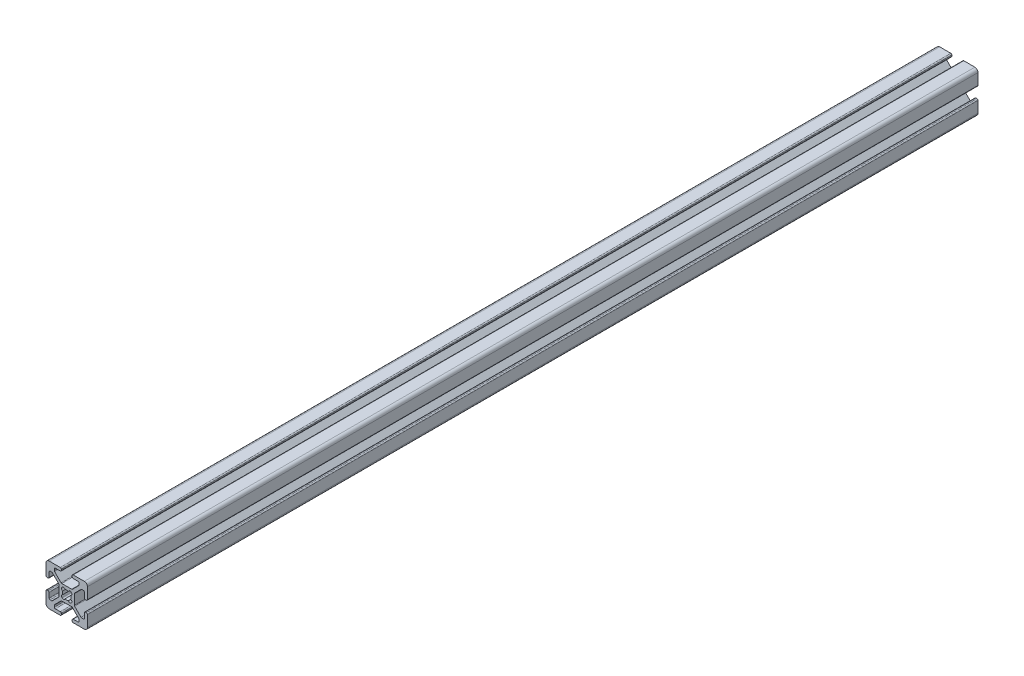
from build123d import *

# Parameters (mm, degrees)
EXTRUDE1_DEPTH = 430


with BuildPart() as part:
    # Sketch1 → Extrude1 (new body)
    with BuildSketch(Plane.XY):
        with BuildLine():
            Line((9.492, 2.63), (9.008, 2.63))
            ThreePointArc((9.008, 2.63), (8.648789755, 2.778789755), (8.5, 3.138))
            Line((8.5, 3.138), (8.5, 5.487))
            ThreePointArc((8.5, 5.487), (8.351210245, 5.846210245), (7.992, 5.995))
            Line((7.992, 5.995), (7.266080661, 5.995))
            ThreePointArc((7.266080661, 5.995), (7.071677478, 5.956330803), (6.906870417, 5.846210245))
            Line((6.906870417, 5.846210245), (3.803789755, 2.743129583))
            ThreePointArc((3.803789755, 2.743129583), (3.693669197, 2.578322522), (3.655, 2.383919339))
            Line((3.655, 2.383919339), (3.655, -2.383919339))
            ThreePointArc((3.655, -2.383919339), (3.693669197, -2.578322522), (3.803789755, -2.743129583))
            Line((3.803789755, -2.743129583), (6.906870417, -5.846210245))
            ThreePointArc((6.906870417, -5.846210245), (7.071677478, -5.956330803), (7.266080661, -5.995))
            Line((7.266080661, -5.995), (7.992, -5.995))
            ThreePointArc((7.992, -5.995), (8.351210245, -5.846210245), (8.5, -5.487))
            Line((8.5, -5.487), (8.5, -3.138))
            ThreePointArc((8.5, -3.138), (8.648789755, -2.778789755), (9.008, -2.63))
            Line((9.008, -2.63), (9.492, -2.63))
            ThreePointArc((9.492, -2.63), (9.851210245, -2.778789755), (10, -3.138))
            Line((10, -3.138), (10, -8.5))
            ThreePointArc((10, -8.5), (9.560660172, -9.560660172), (8.5, -10))
            Line((8.5, -10), (3.138, -10))
            ThreePointArc((3.138, -10), (2.778789755, -9.851210245), (2.63, -9.492))
            Line((2.63, -9.492), (2.63, -9.008))
            ThreePointArc((2.63, -9.008), (2.778789755, -8.648789755), (3.138, -8.5))
            Line((3.138, -8.5), (5.487, -8.5))
            ThreePointArc((5.487, -8.5), (5.846210245, -8.351210245), (5.995, -7.992))
            Line((5.995, -7.992), (5.995, -7.266080661))
            ThreePointArc((5.995, -7.266080661), (5.956330803, -7.071677478), (5.846210245, -6.906870417))
            Line((5.846210245, -6.906870417), (2.743129583, -3.803789755))
            ThreePointArc((2.743129583, -3.803789755), (2.578322522, -3.693669197), (2.383919339, -3.655))
            Line((2.383919339, -3.655), (-2.383919339, -3.655))
            ThreePointArc((-2.383919339, -3.655), (-2.578322522, -3.693669197), (-2.743129583, -3.803789755))
            Line((-2.743129583, -3.803789755), (-5.846210245, -6.906870417))
            ThreePointArc((-5.846210245, -6.906870417), (-5.956330803, -7.071677478), (-5.995, -7.266080661))
            Line((-5.995, -7.266080661), (-5.995, -7.992))
            ThreePointArc((-5.995, -7.992), (-5.846210245, -8.351210245), (-5.487, -8.5))
            Line((-5.487, -8.5), (-3.138, -8.5))
            ThreePointArc((-3.138, -8.5), (-2.778789755, -8.648789755), (-2.63, -9.008))
            Line((-2.63, -9.008), (-2.63, -9.492))
            ThreePointArc((-2.63, -9.492), (-2.778789755, -9.851210245), (-3.138, -10))
            Line((-3.138, -10), (-8.5, -10))
            ThreePointArc((-8.5, -10), (-9.560660172, -9.560660172), (-10, -8.5))
            Line((-10, -8.5), (-10, -3.138))
            ThreePointArc((-10, -3.138), (-9.851210245, -2.778789755), (-9.492, -2.63))
            Line((-9.492, -2.63), (-9.008, -2.63))
            ThreePointArc((-9.008, -2.63), (-8.648789755, -2.778789755), (-8.5, -3.138))
            Line((-8.5, -3.138), (-8.5, -5.487))
            ThreePointArc((-8.5, -5.487), (-8.351210245, -5.846210245), (-7.992, -5.995))
            Line((-7.992, -5.995), (-7.266080661, -5.995))
            ThreePointArc((-7.266080661, -5.995), (-7.071677478, -5.956330803), (-6.906870417, -5.846210245))
            Line((-6.906870417, -5.846210245), (-3.803789755, -2.743129583))
            ThreePointArc((-3.803789755, -2.743129583), (-3.693669197, -2.578322522), (-3.655, -2.383919339))
            Line((-3.655, -2.383919339), (-3.655, 2.383919339))
            ThreePointArc((-3.655, 2.383919339), (-3.693669197, 2.578322522), (-3.803789755, 2.743129583))
            Line((-3.803789755, 2.743129583), (-6.906870417, 5.846210245))
            ThreePointArc((-6.906870417, 5.846210245), (-7.071677478, 5.956330803), (-7.266080661, 5.995))
            Line((-7.266080661, 5.995), (-7.992, 5.995))
            ThreePointArc((-7.992, 5.995), (-8.351210245, 5.846210245), (-8.5, 5.487))
            Line((-8.5, 5.487), (-8.5, 3.138))
            ThreePointArc((-8.5, 3.138), (-8.648789755, 2.778789755), (-9.008, 2.63))
            Line((-9.008, 2.63), (-9.492, 2.63))
            ThreePointArc((-9.492, 2.63), (-9.851210245, 2.778789755), (-10, 3.138))
            Line((-10, 3.138), (-10, 8.5))
            ThreePointArc((-10, 8.5), (-9.560660172, 9.560660172), (-8.5, 10))
            Line((-8.5, 10), (-3.138, 10))
            ThreePointArc((-3.138, 10), (-2.778789755, 9.851210245), (-2.63, 9.492))
            Line((-2.63, 9.492), (-2.63, 9.008))
            ThreePointArc((-2.63, 9.008), (-2.778789755, 8.648789755), (-3.138, 8.5))
            Line((-3.138, 8.5), (-5.487, 8.5))
            ThreePointArc((-5.487, 8.5), (-5.846210245, 8.351210245), (-5.995, 7.992))
            Line((-5.995, 7.992), (-5.995, 7.266080661))
            ThreePointArc((-5.995, 7.266080661), (-5.956330803, 7.071677478), (-5.846210245, 6.906870417))
            Line((-5.846210245, 6.906870417), (-2.743129583, 3.803789755))
            ThreePointArc((-2.743129583, 3.803789755), (-2.578322522, 3.693669197), (-2.383919339, 3.655))
            Line((-2.383919339, 3.655), (2.383919339, 3.655))
            ThreePointArc((2.383919339, 3.655), (2.578322522, 3.693669197), (2.743129583, 3.803789755))
            Line((2.743129583, 3.803789755), (5.846210245, 6.906870417))
            ThreePointArc((5.846210245, 6.906870417), (5.956330803, 7.071677478), (5.995, 7.266080661))
            Line((5.995, 7.266080661), (5.995, 7.992))
            ThreePointArc((5.995, 7.992), (5.846210245, 8.351210245), (5.487, 8.5))
            Line((5.487, 8.5), (3.138, 8.5))
            ThreePointArc((3.138, 8.5), (2.778789755, 8.648789755), (2.63, 9.008))
            Line((2.63, 9.008), (2.63, 9.492))
            ThreePointArc((2.63, 9.492), (2.778789755, 9.851210245), (3.138, 10))
            Line((3.138, 10), (8.5, 10))
            ThreePointArc((8.5, 10), (9.560660172, 9.560660172), (10, 8.5))
            Line((10, 8.5), (10, 3.138))
            ThreePointArc((10, 3.138), (9.851210245, 2.778789755), (9.492, 2.63))
        make_face()
        with BuildLine():
            Line((2.124900844, -2.304505966), (2.304505966, -2.124900844))
            ThreePointArc((2.304505966, -2.124900844), (2.505938017, -1.356467811), (1.935133506, -0.803976718))
            ThreePointArc((1.935133506, -0.803976718), (2.0955, 0), (1.935133506, 0.803976718))
            ThreePointArc((1.935133506, 0.803976718), (2.505938017, 1.356467811), (2.304505966, 2.124900844))
            Line((2.304505966, 2.124900844), (2.124900844, 2.304505966))
            ThreePointArc((2.124900844, 2.304505966), (1.356467811, 2.505938017), (0.803976718, 1.935133506))
            ThreePointArc((0.803976718, 1.935133506), (0, 2.0955), (-0.803976718, 1.935133506))
            ThreePointArc((-0.803976718, 1.935133506), (-1.356467811, 2.505938017), (-2.124900844, 2.304505966))
            Line((-2.124900844, 2.304505966), (-2.304505966, 2.124900844))
            ThreePointArc((-2.304505966, 2.124900844), (-2.505938017, 1.356467811), (-1.935133506, 0.803976718))
            ThreePointArc((-1.935133506, 0.803976718), (-2.0955, 0), (-1.935133506, -0.803976718))
            ThreePointArc((-1.935133506, -0.803976718), (-2.505938017, -1.356467811), (-2.304505966, -2.124900844))
            Line((-2.304505966, -2.124900844), (-2.124900844, -2.304505966))
            ThreePointArc((-2.124900844, -2.304505966), (-1.356467811, -2.505938017), (-0.803976718, -1.935133506))
            ThreePointArc((-0.803976718, -1.935133506), (0, -2.0955), (0.803976718, -1.935133506))
            ThreePointArc((0.803976718, -1.935133506), (1.356467811, -2.505938017), (2.124900844, -2.304505966))
        make_face(mode=Mode.SUBTRACT)
    extrude(amount=-EXTRUDE1_DEPTH)


solid = part.part
